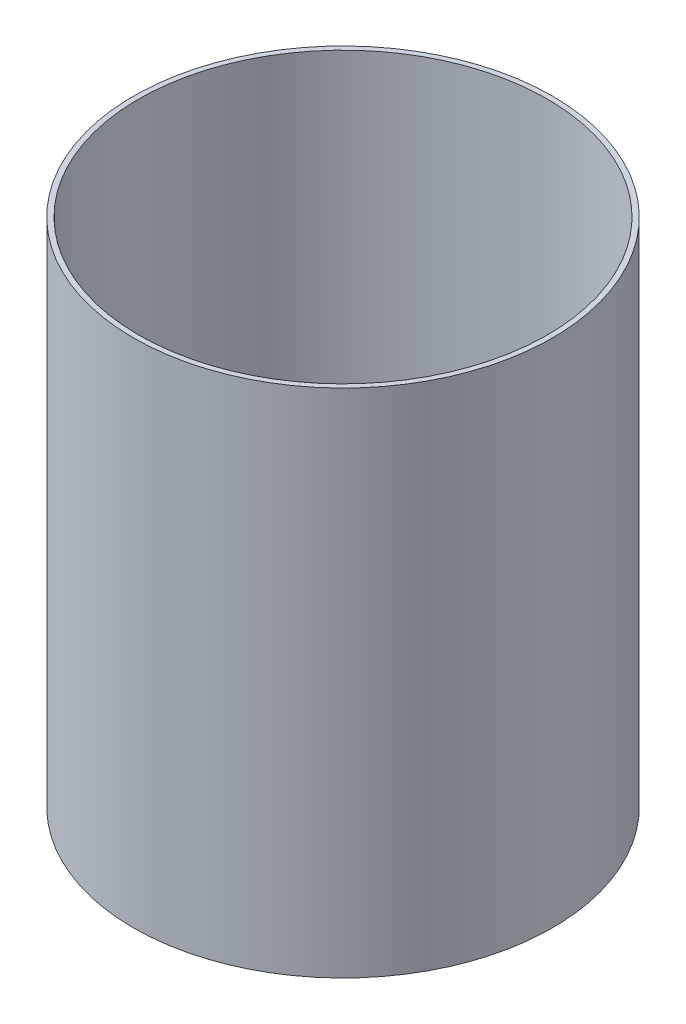
from build123d import *

# Parameters (mm, degrees)
ESBO_O1_R                = 102.5
ESBO_O1_R_2              = 100
RESSALTO_EXTRUS_O1_DEPTH = 250


with BuildPart() as part:
    # Esboço1 → Ressalto-extrusão1 (new body)
    with BuildSketch(Plane(origin=(0, 0, 0), x_dir=(1, 0, 0), z_dir=(0, 1, 0))):
        Circle(ESBO_O1_R)
        Circle(ESBO_O1_R_2, mode=Mode.SUBTRACT)
    extrude(amount=RESSALTO_EXTRUS_O1_DEPTH)


solid = part.part
